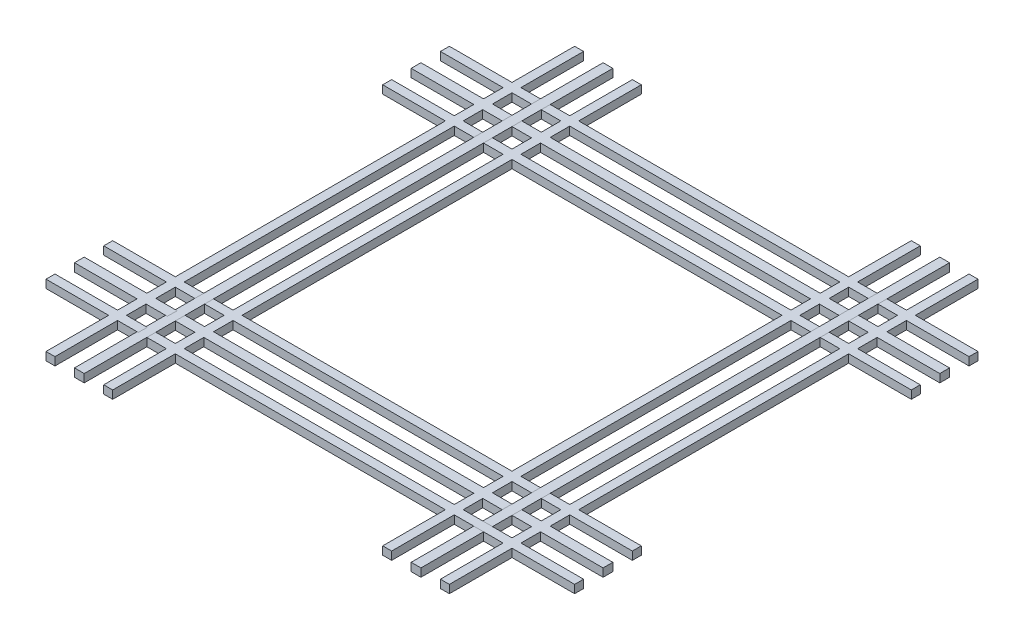
from build123d import *

# Parameters (mm, degrees)
SKETCH_1_W               = 120
SKETCH_1_H               = 6500
EXTRUDE_1_DEPTH          = 100
PATTERN_LINEAR_1_COUNT   = 2
PATTERN_LINEAR_1_PITCH   = 4140
PATTERN_CIRCULAR_1_COUNT = 2
PATTERN_CIRCULAR_1_ANGLE = 90
SKETCH_4_W               = 110
SKETCH_4_H               = 6500
EXTRUDE_2_DEPTH          = 100
PATTERN_CIRCULAR_3_COUNT = 4
SKETCH_5_W               = 110
SKETCH_5_H               = 6500
EXTRUDE_3_DEPTH          = 100
PATTERN_CIRCULAR_4_COUNT = 4


with BuildPart() as part:
    # 草图1 → 凸台-拉伸1 (new body)
    with BuildSketch(Plane(origin=(0, 0, 0), x_dir=(1, 0, 0), z_dir=(0, 1, 0))):
        with Locations((60, 3250)):
            Rectangle(SKETCH_1_W, SKETCH_1_H)
    extrude(amount=EXTRUDE_1_DEPTH)


with BuildPart() as pattern_linear_1_1:
    # 阵列(线性)1: pattern copy
    add(part.part.moved(Location(Vector(1, 0, 0) * (1 * PATTERN_LINEAR_1_PITCH))))


with BuildPart() as pattern_circular_1_1:
    # 阵列(圆周)1: pattern copy
    add(part.part.rotate(Axis((2130, 0, -3250), (0, 1, 0)), 1 * PATTERN_CIRCULAR_1_ANGLE / (PATTERN_CIRCULAR_1_COUNT - 1)))



with BuildPart() as pattern_circular_1_2:
    # 阵列(圆周)1: pattern copy
    add(pattern_linear_1_1.part.rotate(Axis((2130, 0, -3250), (0, 1, 0)), 1 * PATTERN_CIRCULAR_1_ANGLE / (PATTERN_CIRCULAR_1_COUNT - 1)))


with BuildPart() as pattern_circular_1_1_1:
    add(pattern_circular_1_1.part)

    add(pattern_circular_1_2.part)  # 凸台-拉伸2 merges 阵列(圆周)1_2
    # 草图4 → 凸台-拉伸2 (add)
    with BuildSketch(Plane(origin=(0, 100, 0), x_dir=(1, 0, 0), z_dir=(0, 1, 0))):
        with Locations((415, 3250)):
            Rectangle(SKETCH_4_W, SKETCH_4_H)
    extrude_2 = extrude(amount=-EXTRUDE_2_DEPTH)

    # 阵列(圆周)3: 凸台-拉伸2 ×4 about axis
    pattern_circular_3_axis = Axis((2130, 0, -3250), (0, 1, 0))
    for i in range(1, PATTERN_CIRCULAR_3_COUNT):
        add(extrude_2.rotate(pattern_circular_3_axis, i * 360 / PATTERN_CIRCULAR_3_COUNT))

    # 草图5 → 凸台-拉伸3 (add)
    with BuildSketch(Plane(origin=(0, 100, 0), x_dir=(1, 0, 0), z_dir=(0, 1, 0))):
        with Locations((-295, 3250)):
            Rectangle(SKETCH_5_W, SKETCH_5_H)
    extrude_3 = extrude(amount=-EXTRUDE_3_DEPTH)

    # 阵列(圆周)4: 凸台-拉伸3 ×4 about axis
    pattern_circular_4_axis = Axis((2130, 0, -3250), (0, 1, 0))
    for i in range(1, PATTERN_CIRCULAR_4_COUNT):
        add(extrude_3.rotate(pattern_circular_4_axis, i * 360 / PATTERN_CIRCULAR_4_COUNT))


solid = Compound([part.part, pattern_linear_1_1.part, pattern_circular_1_1_1.part])
